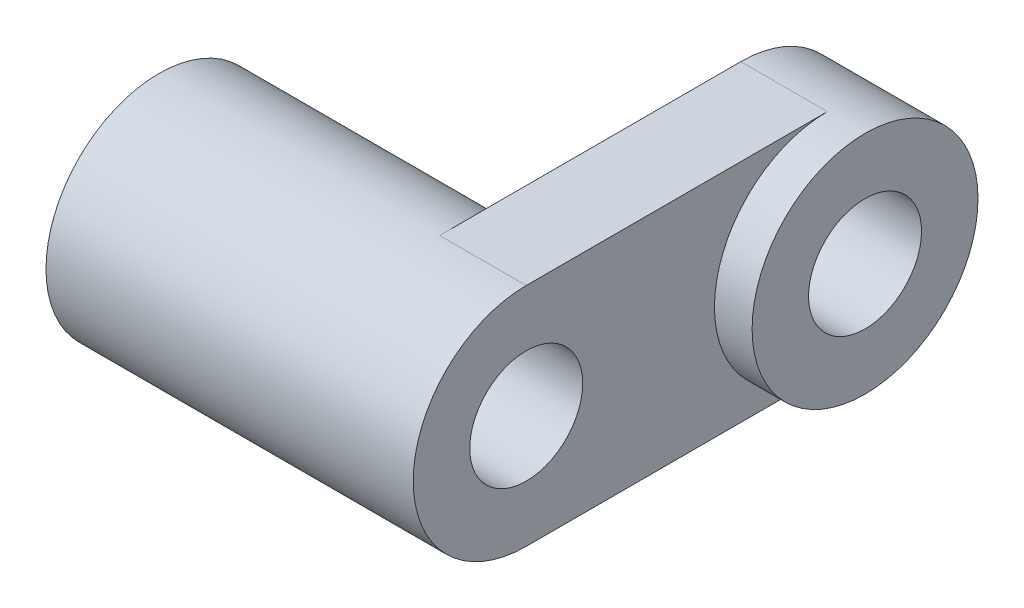
from build123d import *
from build123d.topology import SkipClean

# Parameters (mm, degrees)
SKETCH1_R           = 1.5
BOSS_EXTRUDE1_DEPTH = 2.3
SKETCH2_R           = 3
SKETCH2_R_2         = 1.5
BOSS_EXTRUDE2_DEPTH = 7.455
SKETCH3_R           = 3
SKETCH3_R_2         = 1.5
BOSS_EXTRUDE3_DEPTH = 1


with BuildPart() as part:
    # Sketch1 → Boss-Extrude1 (new body)
    with BuildSketch(Plane(origin=(0, 0, 0), x_dir=(0, 0, -1), z_dir=(1, 0, 0))):
        with BuildLine():
            Line((0, 3), (8, 3))
            ThreePointArc((8, 3), (11, 0), (8, -3))
            Line((8, -3), (0, -3))
            ThreePointArc((0, -3), (-3, 0), (0, 3))
        make_face()
        Circle(SKETCH1_R, mode=Mode.SUBTRACT)
        with Locations((8, 0)):
            Circle(SKETCH1_R, mode=Mode.SUBTRACT)
    extrude(amount=BOSS_EXTRUDE1_DEPTH)

    # Sketch2 → Boss-Extrude2 (add)
    with SkipClean():  # the faces are left unmerged after this step: merging them gives an invalid solid
        with BuildSketch(Plane.ZY):
            with Locations(Location((0, 0, 0), (0, 0, 90))):
                Circle(SKETCH2_R)
            with Locations(Location((0, 0, 0), (0, 0, 180))):
                Circle(SKETCH2_R_2, mode=Mode.SUBTRACT)
        extrude(amount=BOSS_EXTRUDE2_DEPTH)

    # Sketch3 → Boss-Extrude3 (add)
    with SkipClean():  # the faces are left unmerged after this step: merging them gives an invalid solid
        with BuildSketch(Plane(origin=(2.3, 0, 0), x_dir=(0, 0, -1), z_dir=(1, 0, 0))):
            with Locations(Location((8, 0, 0), (0, 0, 90))):
                Circle(SKETCH3_R)
            with Locations((8, 0)):
                Circle(SKETCH3_R_2, mode=Mode.SUBTRACT)
        extrude(amount=BOSS_EXTRUDE3_DEPTH)


solid = part.part
